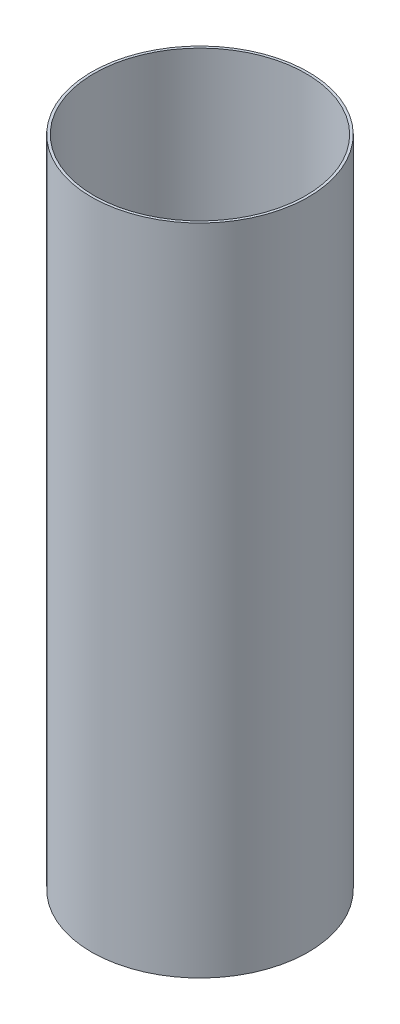
from build123d import *

# Parameters (mm, degrees)
SKETCH1_R           = 33.16
SKETCH1_R_2         = 32.385
BOSS_EXTRUDE1_DEPTH = 100


with BuildPart() as part:
    # Sketch1 → Boss-Extrude1 (new body, symmetric)
    with BuildSketch(Plane(origin=(0, 0, 0), x_dir=(1, 0, 0), z_dir=(0, 1, 0))):
        Circle(SKETCH1_R)
        Circle(SKETCH1_R_2, mode=Mode.SUBTRACT)
    extrude(amount=BOSS_EXTRUDE1_DEPTH, both=True)


solid = part.part
